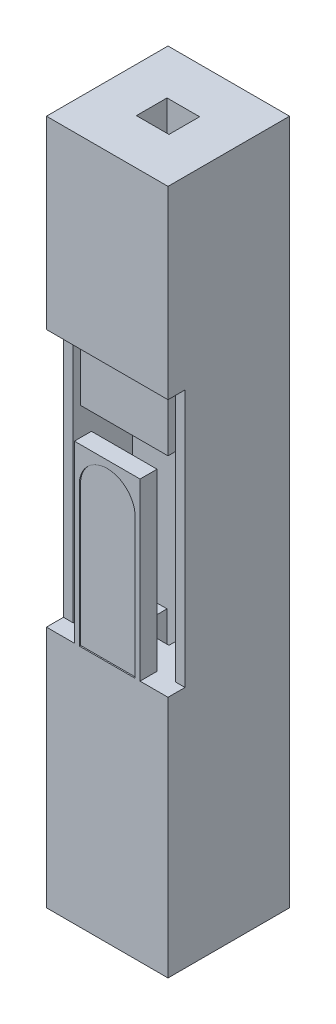
from build123d import *

# Parameters (mm, degrees)
SKETCH2_W           = 2.5
SKETCH2_H           = 2.5
BOSS_EXTRUDE1_DEPTH = 7.05
PINHOLE_REACH       = 16.1
SKETCH3_W           = 0.67
SKETCH3_H           = 0.63
CUT_EXTRUDE2_DEPTH  = 0.35
SKETCH5_W           = 2.1
SKETCH5_H           = 5.3
CUT_EXTRUDE3_DEPTH  = 1.215
CUT_EXTRUDE5_DEPTH  = 0.025
SKETCH7_W           = 2.1
SKETCH7_H           = 2.1
CUT_EXTRUDE6_DEPTH  = 4
SKETCH9_W           = 0.15
SKETCH9_H           = 1
HOLDER_1_DEPTH      = 1.065
SKETCH10_W          = 1.8
SKETCH10_H          = 1
HOLDER_2_DEPTH      = 0.15


with BuildPart() as part:
    # Sketch2 → Boss-Extrude1 (new body, symmetric)
    with BuildSketch(Plane(origin=(0, 0, 0), x_dir=(1, 0, 0), z_dir=(0, 1, 0))):
        Rectangle(SKETCH2_W, SKETCH2_H)
    extrude(amount=BOSS_EXTRUDE1_DEPTH, both=True)

    # Sketch3 → Pinhole (cut, up to next)
    with BuildSketch(Plane(origin=(0, 7.05, 0), x_dir=(1, 0, 0), z_dir=(0, 1, 0)), mode=Mode.PRIVATE) as pinhole_sk1:
        Rectangle(SKETCH3_W, SKETCH3_H)
    pinhole_tool1 = extrude(pinhole_sk1.sketch, amount=-PINHOLE_REACH, mode=Mode.PRIVATE) & part.part
    add(pinhole_tool1.solids().sort_by_distance((0, 7.05, 0))[0], mode=Mode.SUBTRACT)

    # Sketch4 → Cut-Extrude2 (cut)
    with BuildSketch(Plane.XY.offset(1.25)):
        Polygon((-1.25, 3.25), (1.25, 3.25), (1.25, -2.05), (0.675, -2.05), (0.675, 1.55), (-0.675, 1.55), (-0.675, -2.05), (-1.25, -2.05), align=None)
    extrude(amount=-CUT_EXTRUDE2_DEPTH, mode=Mode.SUBTRACT)

    # Sketch5 → Cut-Extrude3 (cut)
    with BuildSketch(Plane.XY.offset(0.9)):
        with Locations((0, 0.6)):
            Rectangle(SKETCH5_W, SKETCH5_H)
    extrude(amount=-CUT_EXTRUDE3_DEPTH, mode=Mode.SUBTRACT)

    # Sketch6 → Cut-Extrude5 (cut)
    with BuildSketch(Plane.XY.offset(1.25)):
        with BuildLine():
            Line((-0.575, 0.825), (-0.575, -2.05))
            Line((-0.575, -2.05), (0.575, -2.05))
            Line((0.575, -2.05), (0.575, 0.825))
            ThreePointArc((0.575, 0.825), (0, 1.4), (-0.575, 0.825))
        make_face()
    extrude(amount=-CUT_EXTRUDE5_DEPTH, mode=Mode.SUBTRACT)

    # Sketch7 → Cut-Extrude6 (cut)
    with BuildSketch(Plane.XZ.offset(7.05)):
        Rectangle(SKETCH7_W, SKETCH7_H)
    extrude(amount=-CUT_EXTRUDE6_DEPTH, mode=Mode.SUBTRACT)

    # Sketch9 → Holder-1 (add)
    with BuildSketch(Plane.XY.offset(-0.315)):
        with Locations((-0.825, 2.4)):
            Rectangle(SKETCH9_W, SKETCH9_H)
        with Locations((0.825, 2.4)):
            Rectangle(SKETCH9_W, SKETCH9_H)
    extrude(amount=HOLDER_1_DEPTH)

    # Sketch10 → Holder-2 (add)
    with BuildSketch(Plane.XY.offset(0.75)):
        with Locations((0, 2.4)):
            Rectangle(SKETCH10_W, SKETCH10_H)
    extrude(amount=HOLDER_2_DEPTH)


solid = part.part
